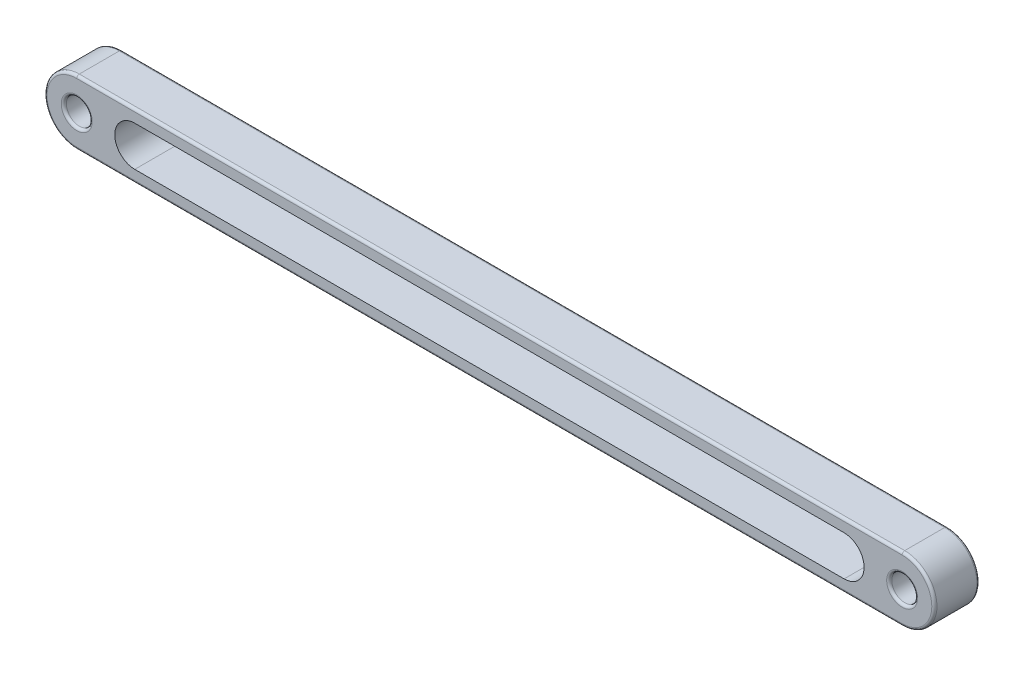
from build123d import *

# Parameters (mm, degrees)
BOSS_EXTRUDE2_DEPTH = 17.5
SKETCH5_R           = 10
CUT_EXTRUDE1_DEPTH  = 36
CUT_EXTRUDE2_DEPTH  = 40
FILLET1_R           = 2


with BuildPart() as part:
    # Sketch4 → Boss-Extrude2 (new body, symmetric)
    with BuildSketch(Plane.XY):
        with BuildLine():
            Line((-320, 25), (320, 25))
            ThreePointArc((320, 25), (345, 0), (320, -25))
            Line((320, -25), (-320, -25))
            ThreePointArc((-320, -25), (-345, 0), (-320, 25))
        make_face()
    extrude(amount=BOSS_EXTRUDE2_DEPTH, both=True)

    # Sketch5 → Cut-Extrude1 (cut, through all)
    with BuildSketch(Plane.XY.offset(17.5)):
        with Locations((320, 0)):
            Circle(SKETCH5_R)
        with Locations((-320, 0)):
            Circle(SKETCH5_R)
    extrude(amount=-CUT_EXTRUDE1_DEPTH, mode=Mode.SUBTRACT)

    # Sketch6 → Cut-Extrude2 (cut)
    with BuildSketch(Plane(origin=(0, 0, -17.5), x_dir=(-1, 0, 0), z_dir=(0, 0, -1))):
        with BuildLine():
            Line((-275, 15.5), (275, 15.5))
            ThreePointArc((275, 15.5), (290.5, 0), (275, -15.5))
            Line((275, -15.5), (-275, -15.5))
            ThreePointArc((-275, -15.5), (-290.5, 0), (-275, 15.5))
        make_face()
    extrude(amount=-CUT_EXTRUDE2_DEPTH, mode=Mode.SUBTRACT)

    # Fillet1
    fillet1_edges = [part.edges().sort_by_distance(p)[0] for p in [
        (345, 0, 17.5),
        (310, 0, -17.5),
        (310, 0, 17.5),
        (0, 25, 17.5),
        (-330, 0, -17.5),
        (-330, 0, 17.5),
        (-345, 0, 17.5),
        (0, 25, -17.5),
        (345, 0, -17.5),
        (0, -25, -17.5),
        (-345, 0, -17.5),
        (0, -25, 17.5),
    ]]
    fillet(fillet1_edges, radius=FILLET1_R)


solid = part.part
